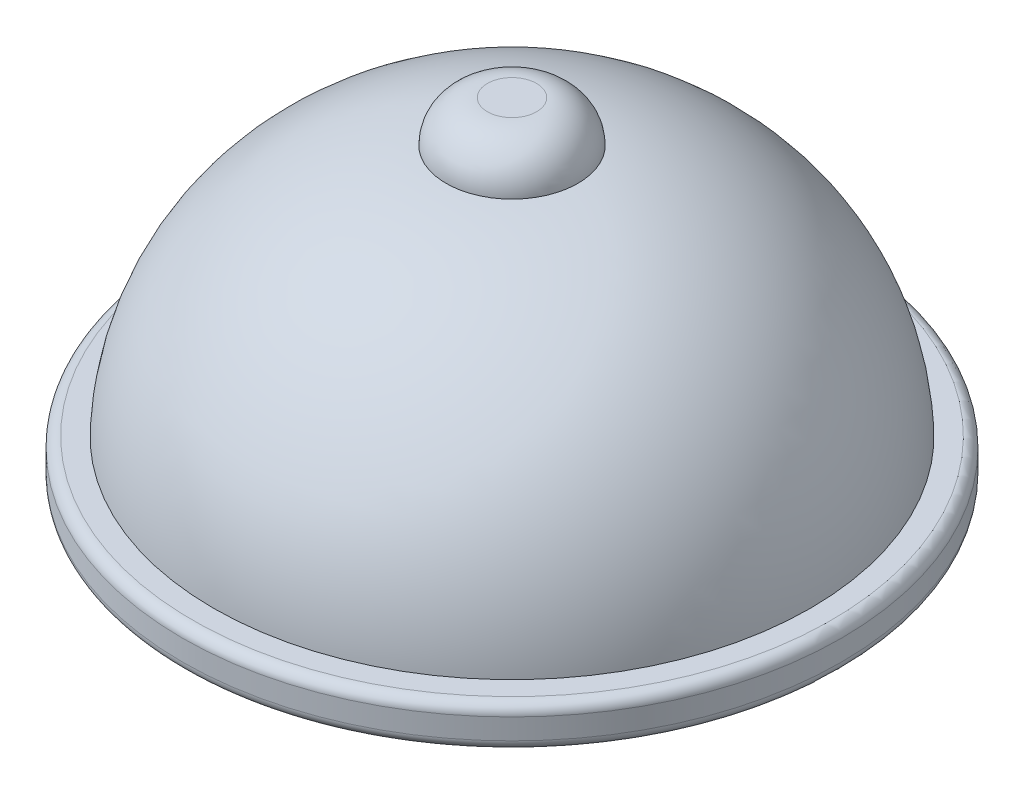
from build123d import *


with BuildPart() as part:
    # Sketch1 → Revolve1 (revolve)
    with BuildSketch(Plane.XY):
        with BuildLine():
            Line((-183.297099868, -161.21177156), (-167.526635099, -161.21177156))
            ThreePointArc((-167.526635099, -161.21177156), (-163.036507039, -159.351899621), (-161.176635099, -154.86177156))
            Line((-161.176635099, -154.86177156), (-161.176635099, -135.81177156))
            ThreePointArc((-161.176635099, -135.81177156), (-126.866331393, -44.771728432), (-40.489374244, 0))
            Line((-40.489374244, 0), (0, 0))
            Line((0, 0), (0, 44.205790237))
            Line((0, 44.205790237), (-15.089374244, 44.205790237))
            ThreePointArc((-15.089374244, 44.205790237), (-33.049886486, 36.766302479), (-40.489374244, 18.805790237))
            ThreePointArc((-40.489374244, 18.805790237), (-140.22189718, -32.338100495), (-183.297099868, -135.81177156))
            Line((-183.297099868, -135.81177156), (-196.040553668, -135.81177156))
            ThreePointArc((-196.040553668, -135.81177156), (-200.530681729, -137.671643499), (-202.390553668, -142.16177156))
            Line((-202.390553668, -142.16177156), (-202.390553668, -154.86177156))
            ThreePointArc((-202.390553668, -154.86177156), (-200.530681729, -159.351899621), (-196.040553668, -161.21177156))
            Line((-196.040553668, -161.21177156), (-183.297099868, -161.21177156))
        make_face()
    revolve(axis=Axis((0, 0, 0), (0, 1, 0)))


solid = part.part
